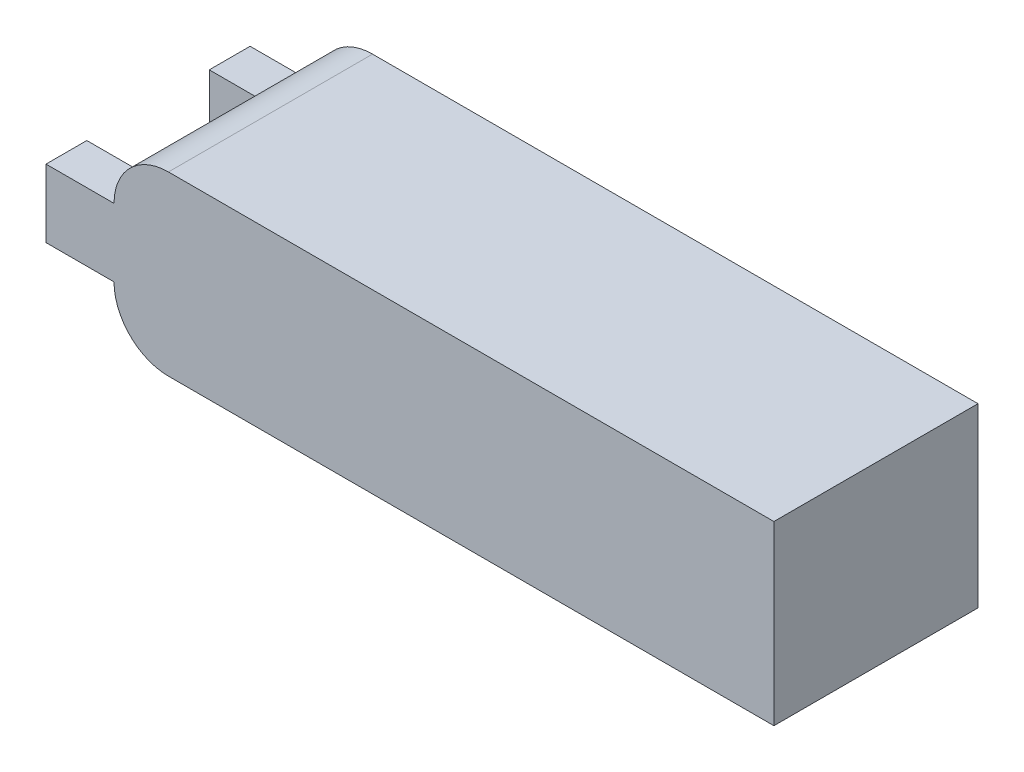
from build123d import *

# Parameters (mm, degrees)
SKETCH1_W           = 97
SKETCH1_H           = 30
BOSS_EXTRUDE1_DEPTH = 26
FILLET1_R           = 8
SKETCH2_W           = 6
SKETCH2_H           = 10
BOSS_EXTRUDE2_DEPTH = 10


with BuildPart() as part:
    # Sketch1 → Boss-Extrude1 (new body)
    with BuildSketch(Plane(origin=(0, 0, 0), x_dir=(1, 0, 0), z_dir=(0, 1, 0))):
        with Locations((48.5, 15)):
            Rectangle(SKETCH1_W, SKETCH1_H)
    extrude(amount=BOSS_EXTRUDE1_DEPTH)

    # Fillet1
    fillet1_edges = [part.edges().sort_by_distance(p)[0] for p in [
        (0, 26, -15),
        (0, 0, -15),
    ]]
    fillet(fillet1_edges, radius=FILLET1_R)

    # Sketch2 → Boss-Extrude2 (add)
    with BuildSketch(Plane.ZY):
        with Locations((-27, 13)):
            Rectangle(SKETCH2_W, SKETCH2_H)
        with Locations((-3, 13)):
            Rectangle(SKETCH2_W, SKETCH2_H)
    extrude(amount=BOSS_EXTRUDE2_DEPTH)


solid = part.part
